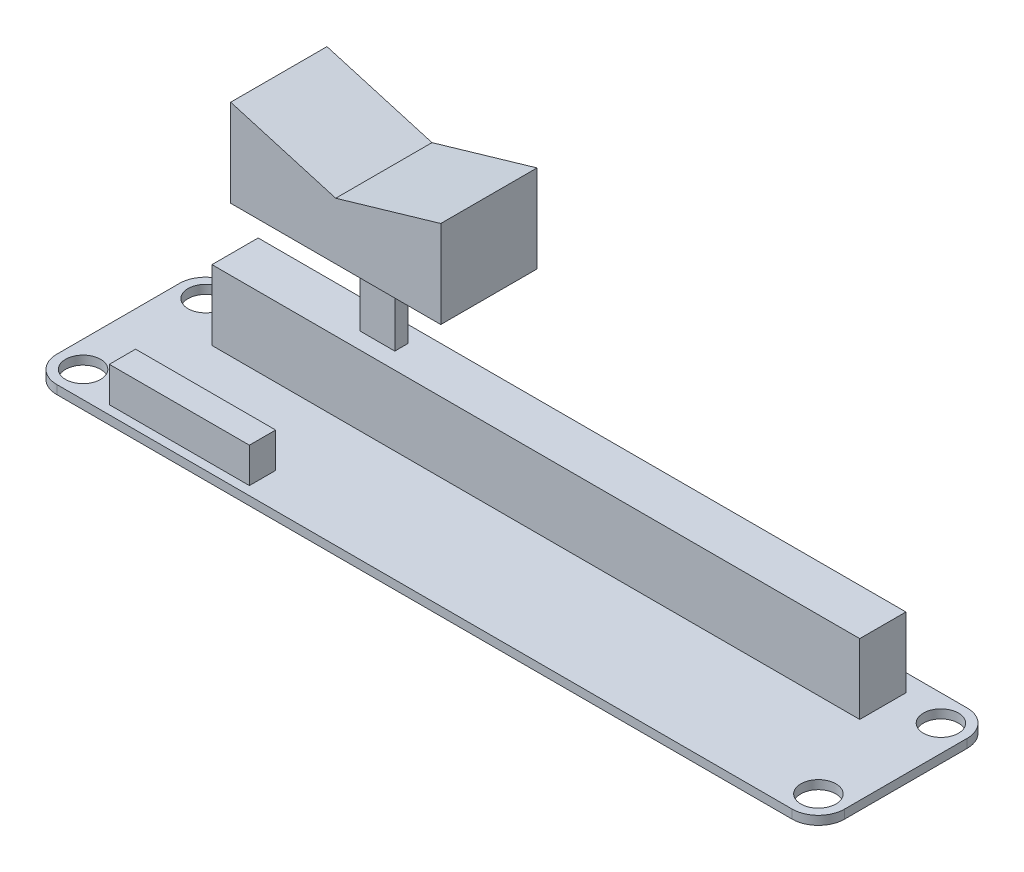
from build123d import *

# Parameters (mm, degrees)
SKETCH1_W           = 90
SKETCH1_H           = 20
BOSS_EXTRUDE1_DEPTH = 1
SKETCH2_R           = 2
CUT_EXTRUDE1_DEPTH  = 2
FILLET1_R           = 3
SKETCH3_W           = 74
SKETCH3_H           = 5.275339083
BOSS_EXTRUDE2_DEPTH = 8
SKETCH4_W           = 16
SKETCH4_H           = 3
BOSS_EXTRUDE3_DEPTH = 4
SKETCH5_W           = 4
SKETCH5_H           = 1.5
BOSS_EXTRUDE4_DEPTH = 10
SKETCH6_W           = 24
SKETCH6_H           = 11
BOSS_EXTRUDE5_DEPTH = 10
CUT_EXTRUDE2_DEPTH  = 12


with BuildPart() as part:
    # Sketch1 → Boss-Extrude1 (new body)
    with BuildSketch(Plane(origin=(0, 0, 0), x_dir=(1, 0, 0), z_dir=(0, 1, 0))):
        with Locations((45, 10)):
            Rectangle(SKETCH1_W, SKETCH1_H)
    extrude(amount=BOSS_EXTRUDE1_DEPTH)

    # Sketch2 → Cut-Extrude1 (cut, through all)
    with BuildSketch(Plane(origin=(0, 1, 0), x_dir=(1, 0, 0), z_dir=(0, 1, 0))):
        with Locations((3, 17)):
            Circle(SKETCH2_R)
        with Locations((87, 17)):
            Circle(SKETCH2_R)
        with Locations((87, 3)):
            Circle(SKETCH2_R)
        with Locations((3, 3)):
            Circle(SKETCH2_R)
    extrude(amount=-CUT_EXTRUDE1_DEPTH, mode=Mode.SUBTRACT)

    # Fillet1
    fillet1_edges = [part.edges().sort_by_distance(p)[0] for p in [
        (0, 0.5, -20),
        (90, 0.5, -20),
        (90, 0.5, 0),
        (0, 0.5, 0),
    ]]
    fillet(fillet1_edges, radius=FILLET1_R)

    # Sketch3 → Boss-Extrude2 (add)
    with BuildSketch(Plane(origin=(0, 1, 0), x_dir=(1, 0, 0), z_dir=(0, 1, 0))):
        with Locations((45, 15.362330459)):
            Rectangle(SKETCH3_W, SKETCH3_H)
    extrude(amount=BOSS_EXTRUDE2_DEPTH)

    # Sketch4 → Boss-Extrude3 (add)
    with BuildSketch(Plane(origin=(0, 1, 0), x_dir=(1, 0, 0), z_dir=(0, 1, 0))):
        with Locations((16, 2.5)):
            Rectangle(SKETCH4_W, SKETCH4_H)
    extrude(amount=BOSS_EXTRUDE3_DEPTH)

    # Sketch5 → Boss-Extrude4 (add)
    with BuildSketch(Plane(origin=(0, 9, 0), x_dir=(1, 0, 0), z_dir=(0, 1, 0))):
        with Locations((25, 15.362330459)):
            Rectangle(SKETCH5_W, SKETCH5_H)
    extrude(amount=BOSS_EXTRUDE4_DEPTH)

    # Sketch6 → Boss-Extrude5 (add)
    with BuildSketch(Plane(origin=(0, 19, 0), x_dir=(1, 0, 0), z_dir=(0, 1, 0))):
        with Locations((25, 15.362330459)):
            Rectangle(SKETCH6_W, SKETCH6_H)
    extrude(amount=BOSS_EXTRUDE5_DEPTH)

    # Sketch7 → Cut-Extrude2 (cut, through all)
    with BuildSketch(Plane.XY.offset(-9.862330459)):
        Polygon((37, 29), (25, 25.5), (13, 29), align=None)
    extrude(amount=-CUT_EXTRUDE2_DEPTH, mode=Mode.SUBTRACT)


solid = part.part
